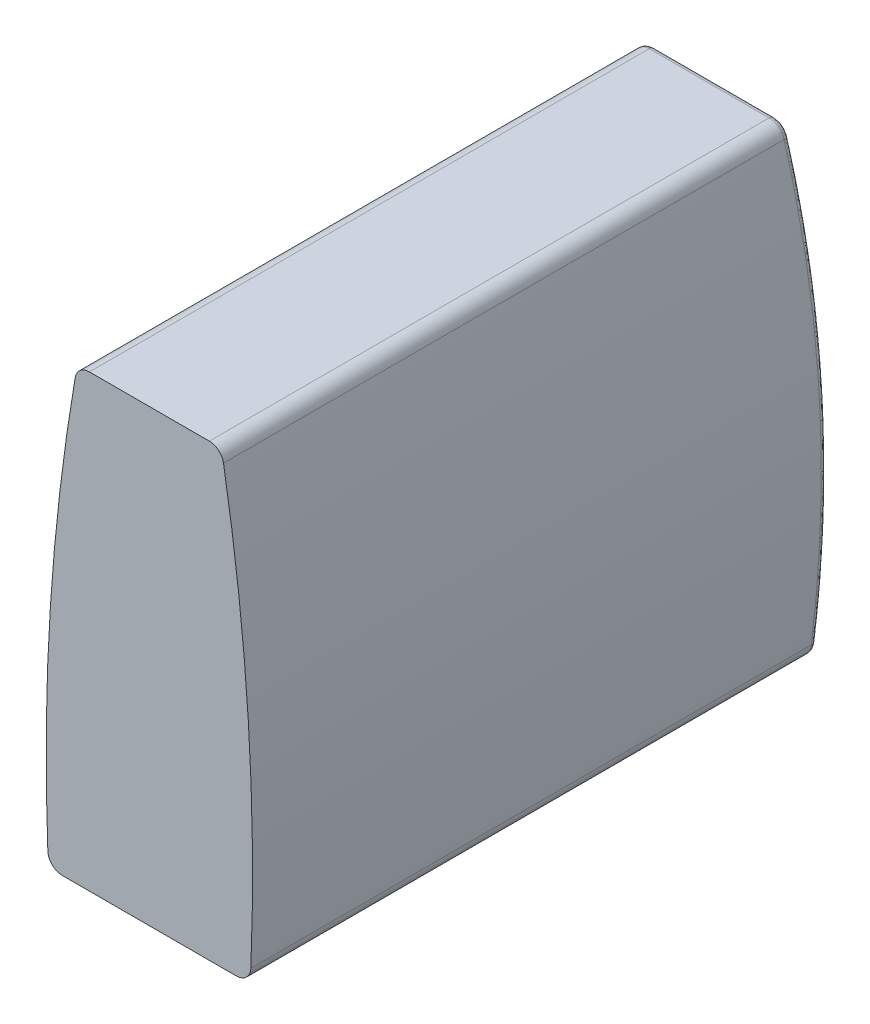
from build123d import *

# Parameters (mm, degrees)
BOSS_EXTRUDE1_DEPTH = 10
CUT_EXTRUDE1_DEPTH  = 5
FILLET1_R           = 0.1


with BuildPart() as part:
    # Sketch1 → Boss-Extrude1 (new body)
    with BuildSketch(Plane.XY):
        with BuildLine():
            Line((-1.039876688, 3.9), (1.039876688, 3.9))
            ThreePointArc((1.039876688, 3.9), (1.201018652, 3.841136777), (1.286277933, 3.692266139))
            ThreePointArc((1.286277933, 3.692266139), (1.717480541, 0.028524691), (1.76066317, -3.660251846))
            ThreePointArc((1.76066317, -3.660251846), (1.683987639, -3.830364855), (1.510873459, -3.9))
            Line((1.510873459, -3.9), (-1.510873459, -3.9))
            ThreePointArc((-1.510873459, -3.9), (-1.683987639, -3.830364855), (-1.76066317, -3.660251846))
            ThreePointArc((-1.76066317, -3.660251846), (-1.717480541, 0.028524691), (-1.286277933, 3.692266139))
            ThreePointArc((-1.286277933, 3.692266139), (-1.201018652, 3.841136777), (-1.039876688, 3.9))
        make_face()
    extrude(amount=BOSS_EXTRUDE1_DEPTH)

    # Sketch2 → Cut-Extrude1 (cut, symmetric)
    with BuildSketch(Plane(origin=(0, 0, 0), x_dir=(0, 0, -1), z_dir=(1, 0, 0))):
        with BuildLine():
            Line((-0.2, 3.9), (0.726559292, 4.710927033))
            Line((0.726559292, 4.710927033), (3.434911983, -0.70577835))
            Line((3.434911983, -0.70577835), (0.497037877, -4.82568774))
            Line((0.497037877, -4.82568774), (-0.2, -3.9))
            ThreePointArc((-0.2, -3.9), (0, 0), (-0.2, 3.9))
        make_face()
    extrude(amount=CUT_EXTRUDE1_DEPTH, both=True, mode=Mode.SUBTRACT)

    # Fillet1
    fillet1_edges = [part.edges().sort_by_distance(p)[0] for p in [
        (0, -3.9, 0.2),
        (1.684192827, -3.830167686, 0.192883786),
        (1.717477583, 0.028570224, 1.0712e-05),
        (-1.717477583, 0.028570224, 1.0712e-05),
        (-1.684192827, -3.830167687, 0.192883786),
        (-1.201207437, 3.840977456, 0.19397685),
        (1.201207437, 3.840977456, 0.19397685),
        (0, 3.9, 0.2),
    ]]
    fillet(fillet1_edges, radius=FILLET1_R)


solid = part.part
